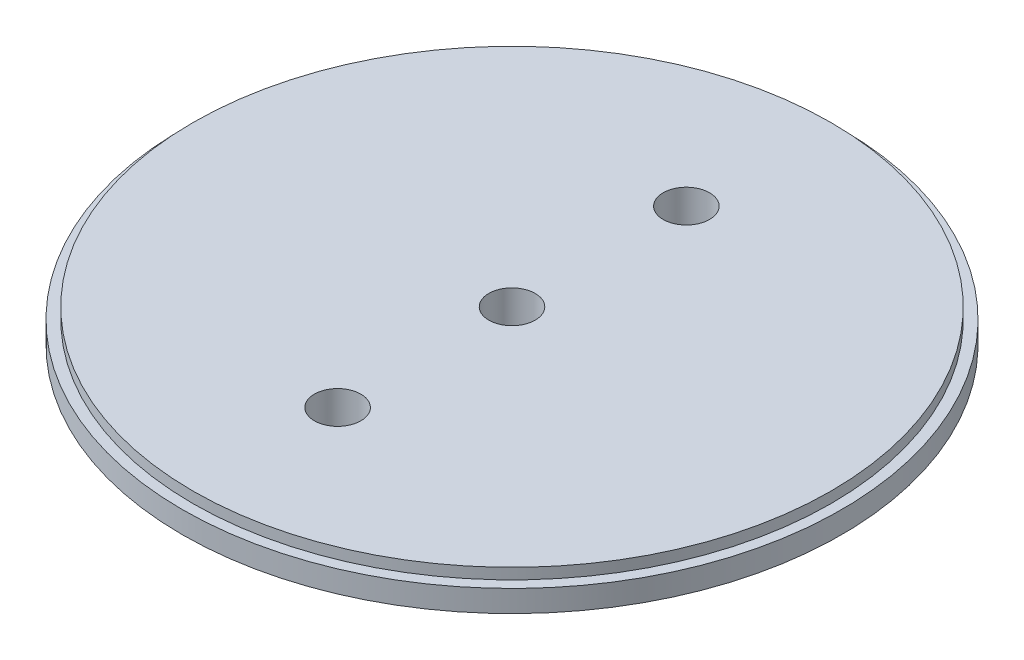
from build123d import *

# Parameters (mm, degrees)
SKETCH1_R               = 48.006
BOSS_EXTRUDE1_DEPTH     = 1.5875
SKETCH2_R               = 46.482
BOSS_EXTRUDE2_DEPTH     = 1.5875
F_1_4_CLEARANCE_HOLE1_D = 6.7564
F_1_4_CLEARANCE_HOLE2_D = 6.7564


with BuildPart() as part:
    # Sketch1 → Boss-Extrude1 (new body, symmetric)
    with BuildSketch(Plane(origin=(0, 0, 0), x_dir=(1, 0, 0), z_dir=(0, 1, 0))):
        Circle(SKETCH1_R)
    extrude(amount=BOSS_EXTRUDE1_DEPTH, both=True)

    # Sketch2 → Boss-Extrude2 (add, symmetric)
    with BuildSketch(Plane(origin=(0, 1.5875, 0), x_dir=(1, 0, 0), z_dir=(0, 1, 0))):
        Circle(SKETCH2_R)
    extrude(amount=BOSS_EXTRUDE2_DEPTH, both=True)

    # 1/4 Clearance Hole1 (through all)
    with Locations(Plane(origin=(0, 3.175, 0), x_dir=(1, 0, 0), z_dir=(0, 1, 0))):
        with Locations((0, 0)):
            Hole(F_1_4_CLEARANCE_HOLE1_D / 2)

    # 1/4 Clearance Hole2 (through all)
    with Locations(Plane(origin=(0, -1.5875, 0), x_dir=(-1, 0, 0), z_dir=(0, -1, 0))):
        with Locations((0, 25.4), (0, -25.4)):
            Hole(F_1_4_CLEARANCE_HOLE2_D / 2)


solid = part.part
